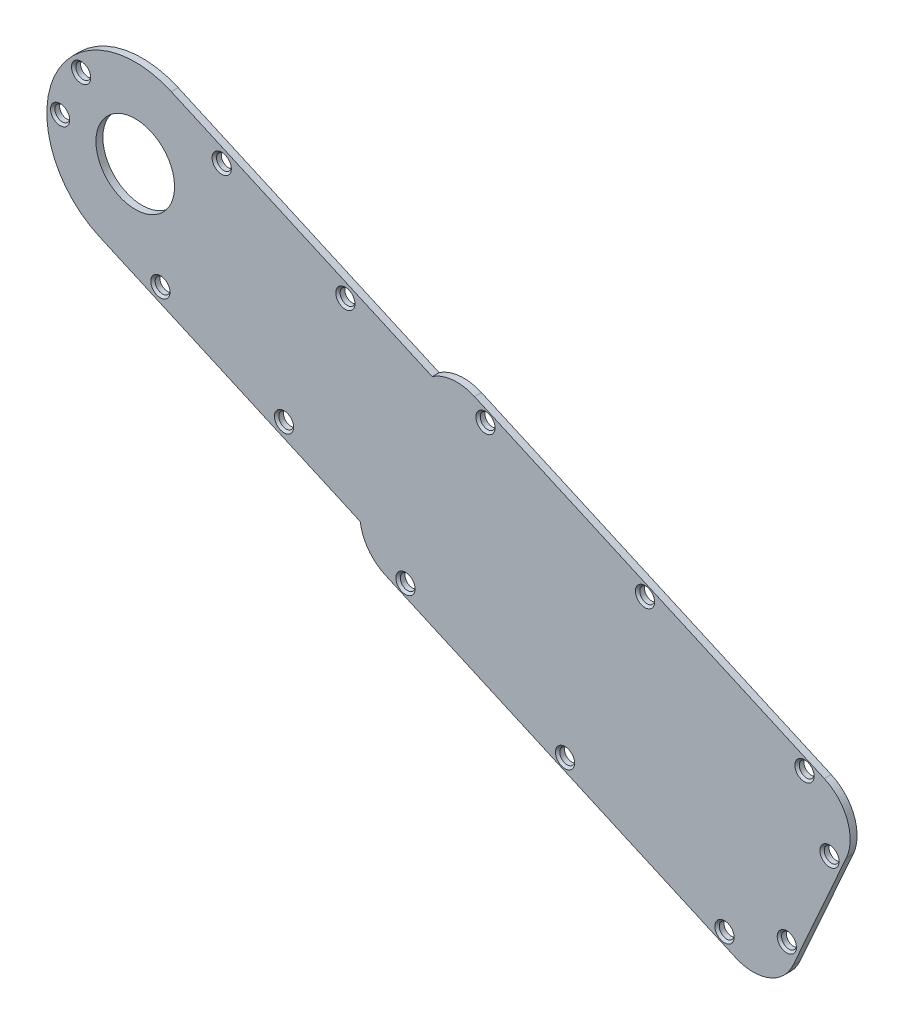
from build123d import *

# Parameters (mm, degrees)
BOSS_EXTRUDE1_DEPTH       = 1.5875
F_4_CLEARANCE_HOLE1_D     = 3.4
F_4_CLEARANCE_HOLE1_DEPTH = 1.5875
HOLE1_D                   = 18
HOLE1_DEPTH               = 1.5875
CHAMFER1_SIZE             = 0.5
FILLET1_R                 = 10


with BuildPart() as part:
    # Sketch1 → Boss-Extrude1 (new body)
    with BuildSketch(Plane.XY.offset(1.5875)):
        with BuildLine():
            Line((-122.373252992, 49.591627472), (-33.137949262, 9.81285715))
            Line((-33.137949262, 9.81285715), (-12.780339067, 55.480873389))
            Line((-12.780339067, 55.480873389), (-102.015642796, 95.25964371))
            ThreePointArc((-102.015642796, 95.25964371), (-106.983028684, 96.085831021), (-111.723245825, 94.386463641))
            Line((-111.723245825, 94.386463641), (-171.498000771, 121.032489918))
            ThreePointArc((-171.498000771, 121.032489918), (-198.238379477, 110.781775471), (-187.98766503, 84.041396765))
            Line((-187.98766503, 84.041396765), (-128.212910083, 57.395370488))
            ThreePointArc((-128.212910083, 57.395370488), (-126.308202352, 52.73386896), (-122.373252992, 49.591627472))
        make_face()
    extrude(amount=-BOSS_EXTRUDE1_DEPTH)

    # #4 Clearance Hole1
    with Locations(Plane.XY.offset(1.5875)):
        with Locations((-99.517086056, 91.408706914), (-62.982673065, 75.122618757), (-26.448260075, 58.836530601), (-20.722062659, 44.787930558), (-30.493715553, 22.867282764), (-44.77010925, 17.735315986), (-81.304522241, 34.021404143), (-117.838935231, 50.307492299), (-131.618242769, 99.970559768), (-145.664993804, 68.459628564), (-173.979163871, 81.081346885), (-159.932412836, 112.592278089), (-192.145991763, 114.525444092), (-196.950263565, 103.748070885)):
            Hole(F_4_CLEARANCE_HOLE1_D / 2, depth=F_4_CLEARANCE_HOLE1_DEPTH)

    # Hole1
    with Locations(Plane(origin=(0, 0, 0), x_dir=(-1, 0, 0), z_dir=(0, 0, -1))):
        with Locations((179.7428329, 102.536943342)):
            Hole(HOLE1_D / 2, depth=HOLE1_DEPTH)

    # Chamfer1
    chamfer1_edges = [part.edges().sort_by_distance(p)[0] for p in [
        (-24.748260075, 58.836530601, 1.5875),
        (-61.282673065, 75.122618757, 1.5875),
        (-97.817086056, 91.408706914, 1.5875),
        (-195.250263565, 103.748070885, 1.5875),
        (-190.445991763, 114.525444092, 1.5875),
        (-158.232412836, 112.592278089, 1.5875),
        (-172.279163871, 81.081346885, 1.5875),
        (-143.964993804, 68.459628564, 1.5875),
        (-129.918242769, 99.970559768, 1.5875),
        (-116.138935231, 50.307492299, 1.5875),
        (-79.604522241, 34.021404143, 1.5875),
        (-43.07010925, 17.735315986, 1.5875),
        (-28.793715553, 22.867282764, 1.5875),
        (-19.022062659, 44.787930558, 1.5875),
    ]]
    chamfer(chamfer1_edges, length=CHAMFER1_SIZE)

    # Fillet1
    fillet1_edges = [part.edges().sort_by_distance(p)[0] for p in [
        (-12.780339067, 55.480873389, 0.79375),
        (-33.137949262, 9.81285715, 0.79375),
    ]]
    fillet(fillet1_edges, radius=FILLET1_R)


solid = part.part
